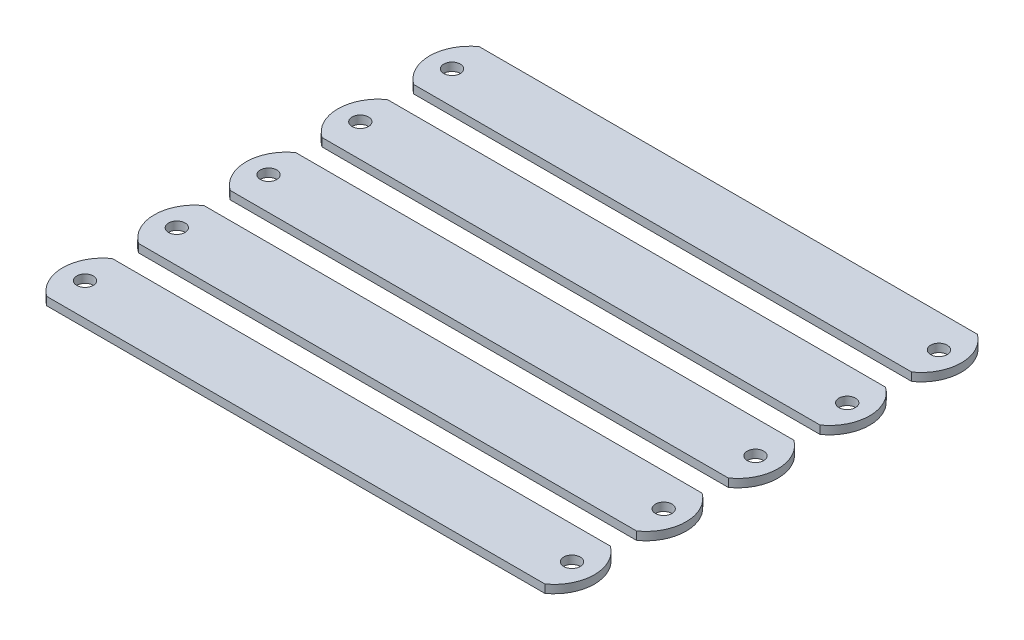
from build123d import *

# Parameters (mm, degrees)
SKETCH1_R           = 1.6002
BOSS_EXTRUDE1_DEPTH = 0.79375
LPATTERN1_COUNT     = 5
LPATTERN1_PITCH     = 17.78


with BuildPart() as part:
    # Sketch1 → Boss-Extrude1 (new body, symmetric)
    with BuildSketch(Plane(origin=(0, 0, 0), x_dir=(1, 0, 0), z_dir=(0, 1, 0))):
        with BuildLine():
            Line((-48.26, -6.35), (48.26, -6.35))
            ThreePointArc((48.26, -6.35), (51.530005533, 0), (48.26, 6.35))
            Line((48.26, 6.35), (-48.26, 6.35))
            ThreePointArc((-48.26, 6.35), (-51.530005511, 0), (-48.26, -6.35))
        make_face()
        with Locations((-47.177105686, 0)):
            Circle(SKETCH1_R, mode=Mode.SUBTRACT)
        with Locations((47.177105686, 0)):
            Circle(SKETCH1_R, mode=Mode.SUBTRACT)
    extrude(amount=BOSS_EXTRUDE1_DEPTH, both=True)


with BuildPart() as lpattern1_1:
    # LPattern1: pattern copy
    add(part.part.moved(Location(Vector(0, 0, -1) * (1 * LPATTERN1_PITCH))))


with BuildPart() as lpattern1_2:
    # LPattern1: pattern copy
    add(part.part.moved(Location(Vector(0, 0, -1) * (2 * LPATTERN1_PITCH))))


with BuildPart() as lpattern1_3:
    # LPattern1: pattern copy
    add(part.part.moved(Location(Vector(0, 0, -1) * (3 * LPATTERN1_PITCH))))


with BuildPart() as lpattern1_4:
    # LPattern1: pattern copy
    add(part.part.moved(Location(Vector(0, 0, -1) * (4 * LPATTERN1_PITCH))))


solid = Compound([part.part, lpattern1_1.part, lpattern1_2.part, lpattern1_3.part, lpattern1_4.part])
